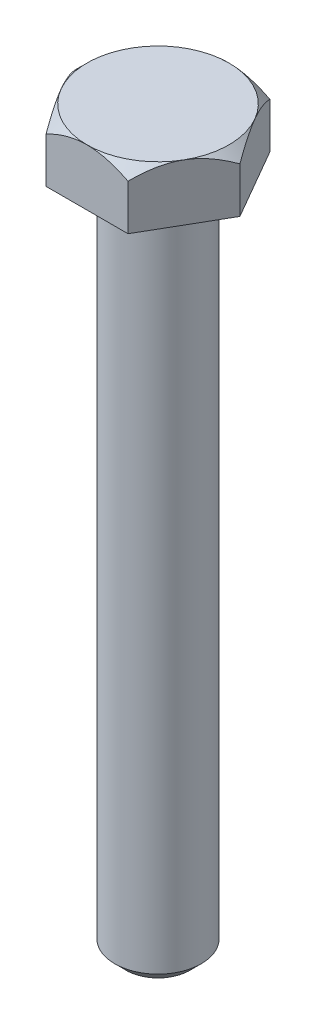
from build123d import *

# Parameters (mm, degrees)
EXTRUDE_1_DEPTH     = 5
SKETCH_8_OUTSIDE_W  = 22.464
SKETCH_8_OUTSIDE_H  = 20.522
SKETCH_8_OUTSIDE_R  = 6.278684177
CUT_EXTRUDE_1_DEPTH = 1
CUT_EXTRUDE_1_DRAFT = -45
SKETCH_9_R          = 3.825
BOLT_LENGTH_DEPTH   = 60
FILLET_1_R          = 1
CHAMFER_1_SIZE      = 1


with BuildPart() as part:
    # Эскиз6 → Бобышка-Вытянуть1 (new body)
    with BuildSketch(Plane(origin=(0, 0, 0), x_dir=(1, 0, 0), z_dir=(0, 1, 0))):
        Polygon((7.25, 0), (3.625, 6.278684177), (-3.625, 6.278684177), (-7.25, 0), (-3.625, -6.278684177), (3.625, -6.278684177), align=None)
    extrude(amount=EXTRUDE_1_DEPTH)


with BuildPart() as cut_extrude_1_tool:
    # Эскиз8 outside → Вырез-Вытянуть1 (with draft: the straight prism first)
    with BuildSketch(Plane(origin=(0, 5, 0), x_dir=(1, 0, 0), z_dir=(0, 1, 0))):
        Rectangle(SKETCH_8_OUTSIDE_W, SKETCH_8_OUTSIDE_H)
        Circle(SKETCH_8_OUTSIDE_R, mode=Mode.SUBTRACT)
    extrude(amount=-CUT_EXTRUDE_1_DEPTH)
    # Вырез-Вытянуть1: the draft: its side faces are tilted about the plane it starts from
    cut_extrude_1_sides = [cut_extrude_1_tool.faces().sort_by_distance(p)[0] for p in [
        (0, 4.5, 10.261),
        (11.232, 4.5, 0),
        (0, 4.5, -10.261),
        (-11.232, 4.5, 0),
        (-6.278684177, 4.5, 0),
    ]]
    draft(cut_extrude_1_sides, Plane(origin=(0, 5, 0), x_dir=(1, 0, 0), z_dir=(0, 1, 0)), CUT_EXTRUDE_1_DRAFT)


with BuildPart() as part_1:
    add(part.part)

    # Вырез-Вытянуть1: cut by cut_extrude_1_tool
    add(cut_extrude_1_tool.part, mode=Mode.SUBTRACT)

    # Эскиз9 → bolt length (add)
    with BuildSketch(Plane.XZ):
        with Locations(Location((0, 0, 0), (0, 0, 90))):  # turned: the seam where the file's is
            Circle(SKETCH_9_R)
    extrude(amount=BOLT_LENGTH_DEPTH)

    # Скругление1
    fillet_1_edges = [part_1.edges().sort_by_distance(p)[0] for p in [
        (0, 0, -3.825),
    ]]
    fillet(fillet_1_edges, radius=FILLET_1_R)

    # Фаска1
    chamfer_1_edges = [part_1.edges().sort_by_distance(p)[0] for p in [
        (0, -60, -3.825),
    ]]
    chamfer(chamfer_1_edges, length=CHAMFER_1_SIZE)


solid = part_1.part
